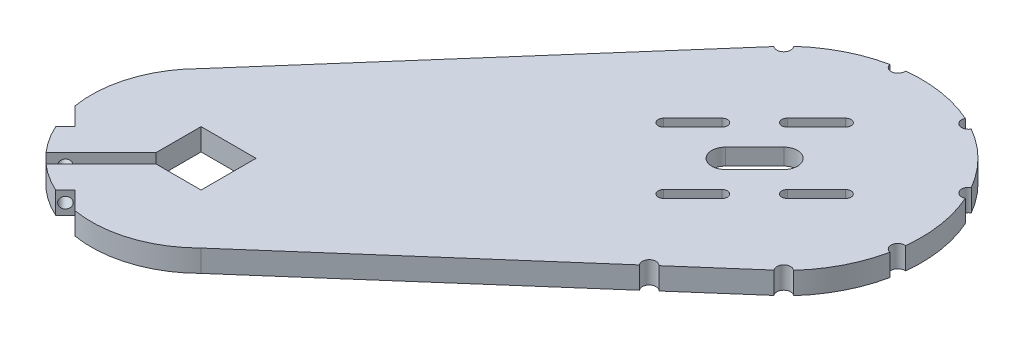
from build123d import *

# Parameters (mm, degrees)
ESQUISSE1_W                  = 20
ESQUISSE1_H                  = 20
BOSS_EXTRU_1_DEPTH           = 8
ENL_V_MAT_EXTRU_1_DEPTH      = 9
ESQUISSE4_R                  = 2
ENL_V_MAT_EXTRU_2_DEPTH      = 142.139610307
ENL_V_MAT_EXTRU_2_DEPTH_BACK = 137.139610307
ENL_V_MAT_EXTRU_3_DEPTH      = 9.0000001
ENL_V_MAT_EXTRU_4_DEPTH      = 9
ESQUISSE9_R                  = 2.5
ENL_V_MAT_EXTRU_6_DEPTH      = 9
ENL_V_MAT_EXTRU_8_DEPTH      = 2


with BuildPart() as part:
    # Esquisse1 → Boss.-Extru.1 (new body)
    with BuildSketch(Plane(origin=(0, 0, 0), x_dir=(1, 0, 0), z_dir=(0, 1, 0))):
        with BuildLine():
            Line((-28.284271247, 28.284271247), (70.710678119, 141.421356237))
            ThreePointArc((70.710678119, 141.421356237), (141.421356237, 141.421356237), (141.421356237, 70.710678119))
            Line((141.421356237, 70.710678119), (28.284271247, -28.284271247))
            ThreePointArc((28.284271247, -28.284271247), (-28.284271247, -28.284271247), (-28.284271247, 28.284271247))
        make_face()
        Rectangle(ESQUISSE1_W, ESQUISSE1_H, mode=Mode.SUBTRACT)
    extrude(amount=BOSS_EXTRU_1_DEPTH)

    # Esquisse3 → Enlèv. mat.-Extru.1 (cut, through all)
    with BuildSketch(Plane(origin=(0, 8, 0), x_dir=(1, 0, 0), z_dir=(0, 1, 0))):
        Polygon((-8.232233047, -11.767766953), (-27.234385984, -30.76991989), (-30.76991989, -27.234385984), (-11.767766953, -8.232233047), (-9.726873799, -6.191339893), (-6.191339893, -9.726873799), align=None)
    extrude(amount=-ENL_V_MAT_EXTRU_1_DEPTH, mode=Mode.SUBTRACT)

    # Esquisse4 → Enlèv. mat.-Extru.2 (cut, two sides)
    with BuildSketch(Plane(origin=(1.767766953, 0, 1.767766953), x_dir=(-0.707106781, 0, 0.707106781), z_dir=(-0.707106781, 0, -0.707106781))) as enl_v_mat_extru_2_sk:
        with Locations((34.921798557, 4)):
            Circle(ESQUISSE4_R)
    extrude(amount=ENL_V_MAT_EXTRU_2_DEPTH, mode=Mode.SUBTRACT)
    extrude(enl_v_mat_extru_2_sk.sketch, amount=-ENL_V_MAT_EXTRU_2_DEPTH_BACK, mode=Mode.SUBTRACT)

    # Esquisse5 → Enlèv. mat.-Extru.3 (cut, through all)
    with BuildSketch(Plane(origin=(0, 8, 0), x_dir=(1, 0, 0), z_dir=(0, 1, 0))):
        Polygon((-34.683660608, -14.703220533), (-36.451427561, -16.470987486), (-40.908486709, -7.777625617), (-39.491104164, -6.360243072), (-32.915893655, -12.93545358), align=None)
        Polygon((-7.777625617, -40.908486709), (-6.360243072, -39.491104164), (-12.93545358, -32.915893655), (-14.703220533, -34.683660608), (-16.470987486, -36.451427561), align=None)
    extrude(amount=-ENL_V_MAT_EXTRU_3_DEPTH, mode=Mode.SUBTRACT)

    # Esquisse7 → Enlèv. mat.-Extru.4 (cut, through all)
    with BuildSketch(Plane(origin=(0, 8, 0), x_dir=(1, 0, 0), z_dir=(0, 1, 0))):
        with BuildLine():
            Line((91.923881554, 98.994949366), (102.530483272, 109.601551084))
            ThreePointArc((102.530483272, 109.601551084), (109.601551084, 109.601551084), (109.601551084, 102.530483272))
            Line((109.601551084, 102.530483272), (98.994949366, 91.923881554))
            ThreePointArc((98.994949366, 91.923881554), (91.923881554, 91.923881554), (91.923881554, 98.994949366))
        make_face()
        with BuildLine():
            Line((94.045201898, 119.373629023), (104.651803616, 129.98023074))
            ThreePointArc((104.651803616, 129.98023074), (107.48023074, 129.98023074), (107.48023074, 127.151803616))
            Line((107.48023074, 127.151803616), (96.873629023, 116.545201898))
            ThreePointArc((96.873629023, 116.545201898), (94.045201898, 116.545201898), (94.045201898, 119.373629023))
        make_face()
        with BuildLine():
            Line((71.545201898, 96.873629023), (82.151803616, 107.48023074))
            ThreePointArc((82.151803616, 107.48023074), (84.98023074, 107.48023074), (84.98023074, 104.651803616))
            Line((84.98023074, 104.651803616), (74.373629023, 94.045201898))
            ThreePointArc((74.373629023, 94.045201898), (71.545201898, 94.045201898), (71.545201898, 96.873629023))
        make_face()
        with BuildLine():
            Line((119.373629023, 94.045201898), (129.98023074, 104.651803616))
            ThreePointArc((129.98023074, 104.651803616), (129.98023074, 107.48023074), (127.151803616, 107.48023074))
            Line((127.151803616, 107.48023074), (116.545201898, 96.873629023))
            ThreePointArc((116.545201898, 96.873629023), (116.545201898, 94.045201898), (119.373629023, 94.045201898))
        make_face()
        with BuildLine():
            Line((96.873629023, 71.545201898), (107.48023074, 82.151803616))
            ThreePointArc((107.48023074, 82.151803616), (107.48023074, 84.98023074), (104.651803616, 84.98023074))
            Line((104.651803616, 84.98023074), (94.045201898, 74.373629023))
            ThreePointArc((94.045201898, 74.373629023), (94.045201898, 71.545201898), (96.873629023, 71.545201898))
        make_face()
    extrude(amount=-ENL_V_MAT_EXTRU_4_DEPTH, mode=Mode.SUBTRACT)

    # Esquisse9 → Enlèv. mat.-Extru.6 (cut, through all)
    with BuildSketch(Plane(origin=(0, 0, 0), x_dir=(-1, 0, 0), z_dir=(0, -1, 0))):
        with Locations((-70.710678119, 141.421356237)):
            Circle(ESQUISSE9_R)
        with Locations((-98.244293926, 155.450434208)):
            Circle(ESQUISSE9_R)
        with Locations((-128.765542165, 150.616343387)):
            Circle(ESQUISSE9_R)
        with Locations((-150.616343387, 128.765542165)):
            Circle(ESQUISSE9_R)
        with Locations((-155.450434208, 98.244293926)):
            Circle(ESQUISSE9_R)
        with Locations((-141.421356237, 70.710678119)):
            Circle(ESQUISSE9_R)
        with Locations((-115.287543419, 47.843591903)):
            Circle(ESQUISSE9_R)
    extrude(amount=-ENL_V_MAT_EXTRU_6_DEPTH, mode=Mode.SUBTRACT)

    # Esquisse11 → Enlèv. mat.-Extru.8 (cut)
    with BuildSketch(Plane(origin=(0, 0, 0), x_dir=(-1, 0, 0), z_dir=(0, -1, 0))):
        with BuildLine():
            Line((-88.388347648, 123.743686708), (-77.781745931, 113.13708499))
            ThreePointArc((-77.781745931, 113.13708499), (-77.781745931, 77.781745931), (-113.13708499, 77.781745931))
            Line((-113.13708499, 77.781745931), (-123.743686708, 88.388347648))
            ThreePointArc((-123.743686708, 88.388347648), (-123.743686708, 123.743686708), (-88.388347648, 123.743686708))
        make_face()
    extrude(amount=-ENL_V_MAT_EXTRU_8_DEPTH, mode=Mode.SUBTRACT)


solid = part.part
